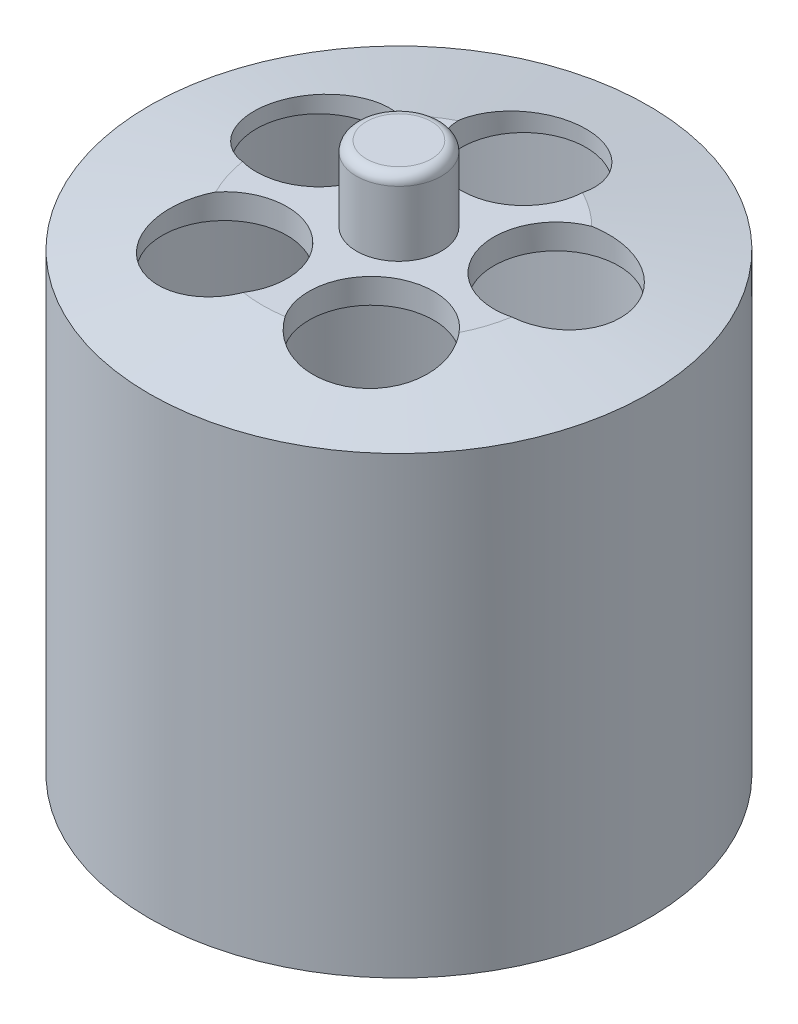
from build123d import *

# Parameters (mm, degrees)
SKETCH1_R           = 63.5
SKETCH1_R_2         = 50.8
BOSS_EXTRUDE1_DEPTH = 114.3
SKETCH2_R           = 63.5
BOSS_EXTRUDE2_DEPTH = 6.35
CHAMFER1_SIZE       = 5.08
CHAMFER1_SIZE2      = 28.810111644
SKETCH3_R           = 15.875
CUT_EXTRUDE1_DEPTH  = 121.65
SKETCH4_R           = 10.795
BOSS_EXTRUDE3_DEPTH = 19.05
FILLET1_R           = 2.54


with BuildPart() as part:
    # Sketch1 → Boss-Extrude1 (new body)
    with BuildSketch(Plane(origin=(0, 0, 0), x_dir=(1, 0, 0), z_dir=(0, 1, 0))):
        Circle(SKETCH1_R)
        Circle(SKETCH1_R_2, mode=Mode.SUBTRACT)
    extrude(amount=BOSS_EXTRUDE1_DEPTH)

    # Sketch2 → Boss-Extrude2 (add)
    with BuildSketch(Plane(origin=(0, 114.3, 0), x_dir=(1, 0, 0), z_dir=(0, 1, 0))):
        Circle(SKETCH2_R)
    extrude(amount=BOSS_EXTRUDE2_DEPTH)

    # Chamfer1
    chamfer1_edges = [part.edges().sort_by_distance(p)[0] for p in [
        (-63.5, 120.65, 0),
    ]]
    chamfer1_side = [part.faces().sort_by_distance(p)[0] for p in [
        (-63.5, 60.325, 0),
    ]]
    chamfer(chamfer1_edges, length=CHAMFER1_SIZE, length2=CHAMFER1_SIZE2, reference=chamfer1_side[0])

    # Sketch3 → Cut-Extrude1 (cut, through all)
    with BuildSketch(Plane(origin=(0, 120.65, 0), x_dir=(1, 0, 0), z_dir=(0, 1, 0))):
        with Locations((0, 31.75)):
            Circle(SKETCH3_R)
        with Locations((30.196044392, 9.811289571)):
            Circle(SKETCH3_R)
        with Locations((18.66218176, -25.686289571)):
            Circle(SKETCH3_R)
        with Locations((-18.66218176, -25.686289571)):
            Circle(SKETCH3_R)
        with Locations((-30.196044392, 9.811289571)):
            Circle(SKETCH3_R)
    extrude(amount=-CUT_EXTRUDE1_DEPTH, mode=Mode.SUBTRACT)

    # Sketch4 → Boss-Extrude3 (add)
    with BuildSketch(Plane(origin=(0, 120.65, 0), x_dir=(1, 0, 0), z_dir=(0, 1, 0))):
        Circle(SKETCH4_R)
    extrude(amount=BOSS_EXTRUDE3_DEPTH)

    # Fillet1
    fillet1_edges = [part.edges().sort_by_distance(p)[0] for p in [
        (-10.795, 139.7, 0),
    ]]
    fillet(fillet1_edges, radius=FILLET1_R)


solid = part.part
